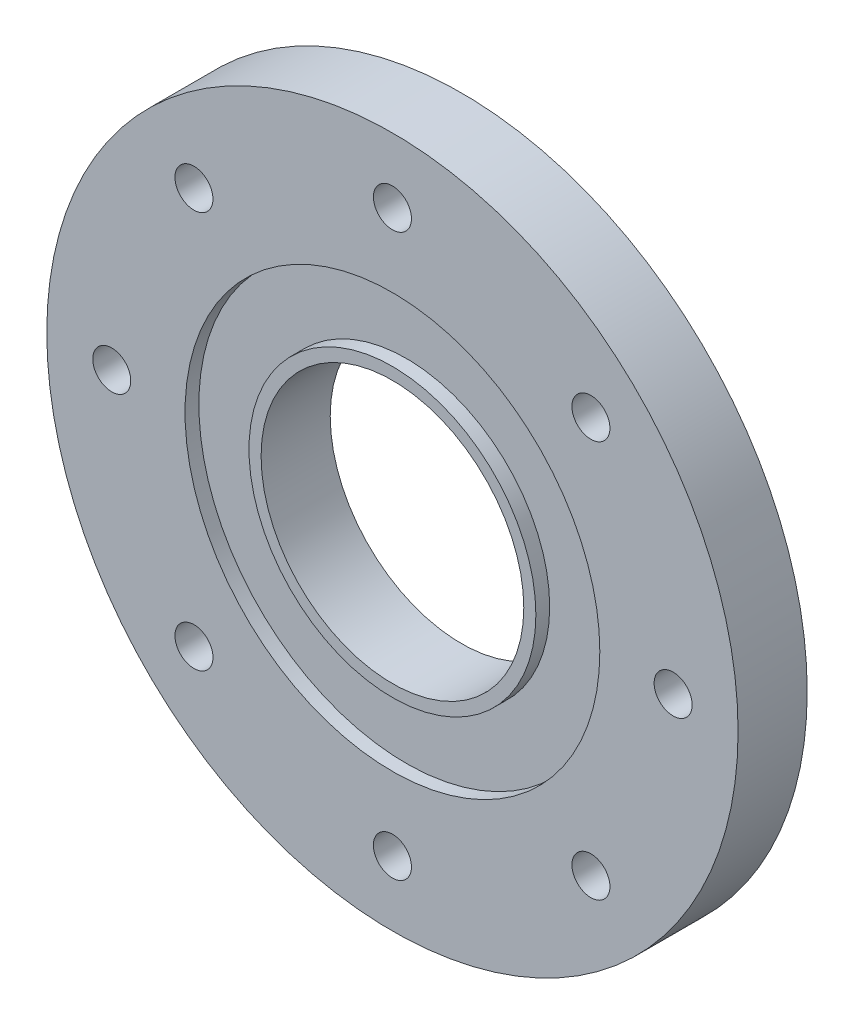
from build123d import *

# Parameters (mm, degrees)
CROQUIS1_R              = 50
CROQUIS1_R_2            = 19
SALIENTE_EXTRUIR1_DEPTH = 10
CROQUIS4_R              = 30
CROQUIS4_R_2            = 20.75
CORTAR_EXTRUIR1_DEPTH   = 2
CROQUIS5_R              = 2.75
CORTAR_EXTRUIR2_DEPTH   = 10


with BuildPart() as part:
    # Croquis1 → Saliente-Extruir1 (new body)
    with BuildSketch(Plane.XY):
        Circle(CROQUIS1_R)
        Circle(CROQUIS1_R_2, mode=Mode.SUBTRACT)
    extrude(amount=SALIENTE_EXTRUIR1_DEPTH)

    # Croquis4 → Cortar-Extruir1 (cut)
    with BuildSketch(Plane.XY.offset(10)):
        Circle(CROQUIS4_R)
        Circle(CROQUIS4_R_2, mode=Mode.SUBTRACT)
    extrude(amount=-CORTAR_EXTRUIR1_DEPTH, mode=Mode.SUBTRACT)

    # Croquis5 → Cortar-Extruir2 (cut)
    with BuildSketch(Plane.XY.offset(10)):
        with Locations((40.602997929, 0)):
            Circle(CROQUIS5_R)
        with Locations((28.710655172, -28.710655172)):
            Circle(CROQUIS5_R)
        with Locations((0, -40.602997929)):
            Circle(CROQUIS5_R)
        with Locations((-28.710655172, -28.710655172)):
            Circle(CROQUIS5_R)
        with Locations((-40.602997929, 0)):
            Circle(CROQUIS5_R)
        with Locations((-28.710655172, 28.710655172)):
            Circle(CROQUIS5_R)
        with Locations((0, 40.602997929)):
            Circle(CROQUIS5_R)
        with Locations((28.710655172, 28.710655172)):
            Circle(CROQUIS5_R)
    extrude(amount=-CORTAR_EXTRUIR2_DEPTH, mode=Mode.SUBTRACT)


solid = part.part
